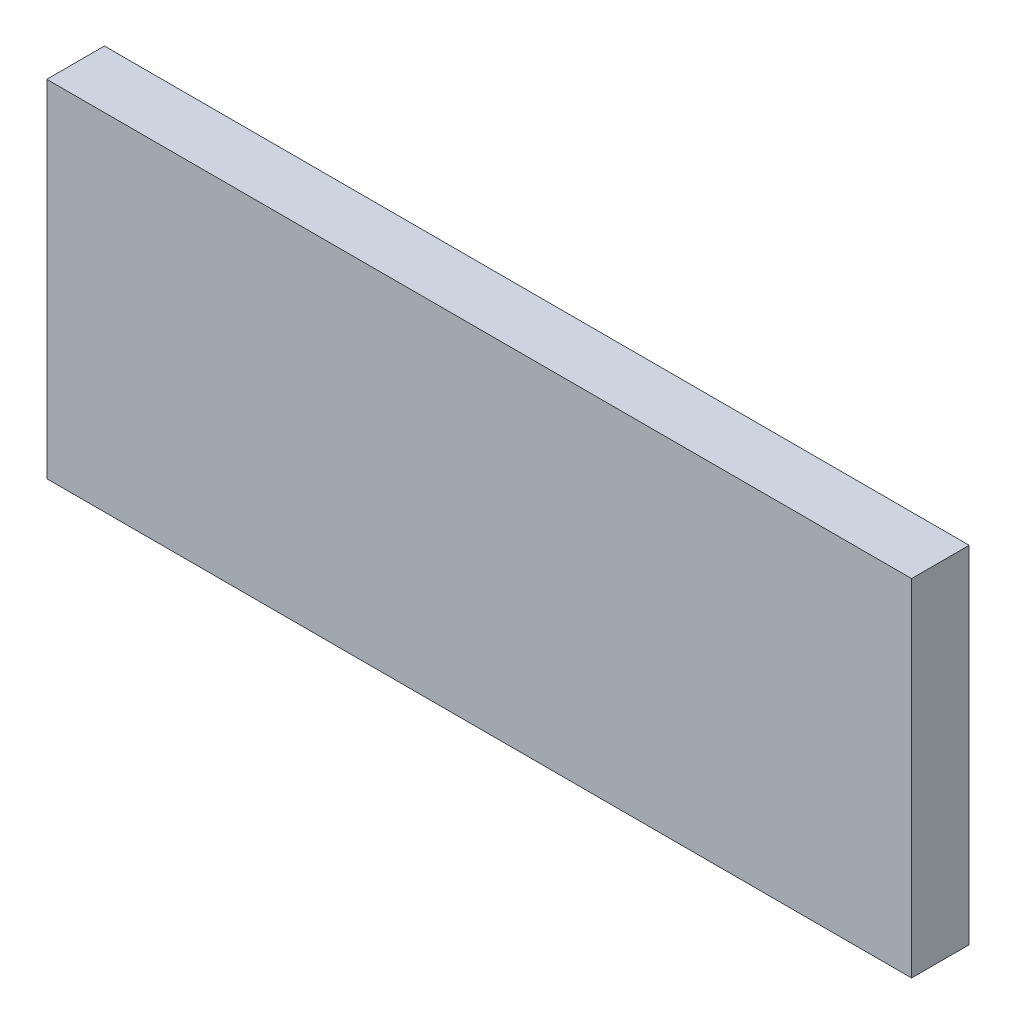
from build123d import *

# Parameters (mm, degrees)
SKETCH1_W           = 76.2
SKETCH1_H           = 30.48
BOSS_EXTRUDE1_DEPTH = 5.08


with BuildPart() as part:
    # Sketch1 → Boss-Extrude1 (new body)
    with BuildSketch(Plane.XY):
        with Locations((-133.888852232, -13.121247947)):
            Rectangle(SKETCH1_W, SKETCH1_H)
    extrude(amount=BOSS_EXTRUDE1_DEPTH)


solid = part.part
